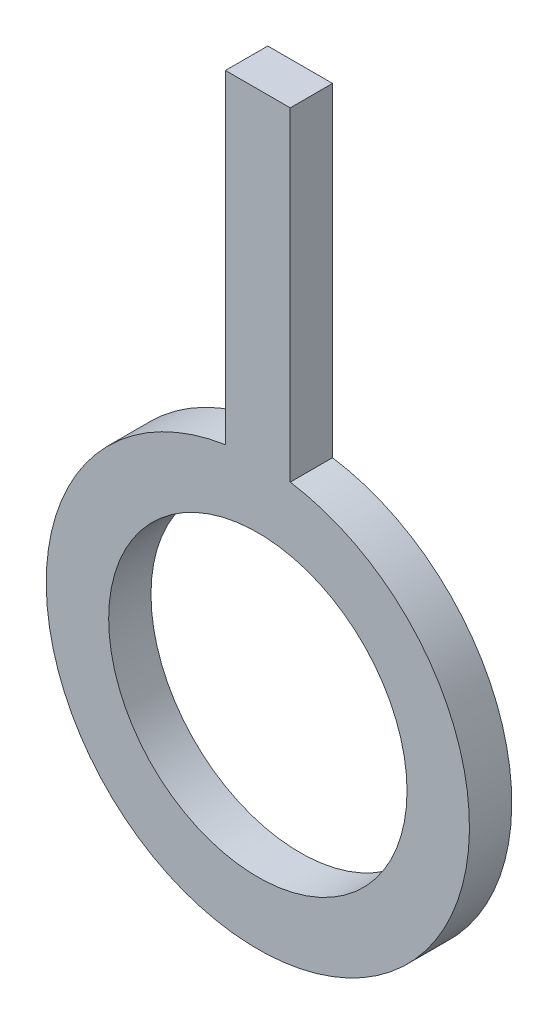
from build123d import *

# Parameters (mm, degrees)
SKETCH1_R           = 7.05
BOSS_EXTRUDE1_DEPTH = 2


with BuildPart() as part:
    # Sketch1 → Boss-Extrude1 (new body)
    with BuildSketch(Plane.XY):
        with BuildLine():
            Line((-1.530931089, 25.199659323), (1.530931089, 25.199659323))
            Line((1.530931089, 25.199659323), (1.530931089, 9.882117688))
            ThreePointArc((1.530931089, 9.882117688), (0, -10), (-1.530931089, 9.882117688))
            Line((-1.530931089, 9.882117688), (-1.530931089, 25.199659323))
        make_face()
        Circle(SKETCH1_R, mode=Mode.SUBTRACT)
    extrude(amount=BOSS_EXTRUDE1_DEPTH)


solid = part.part
